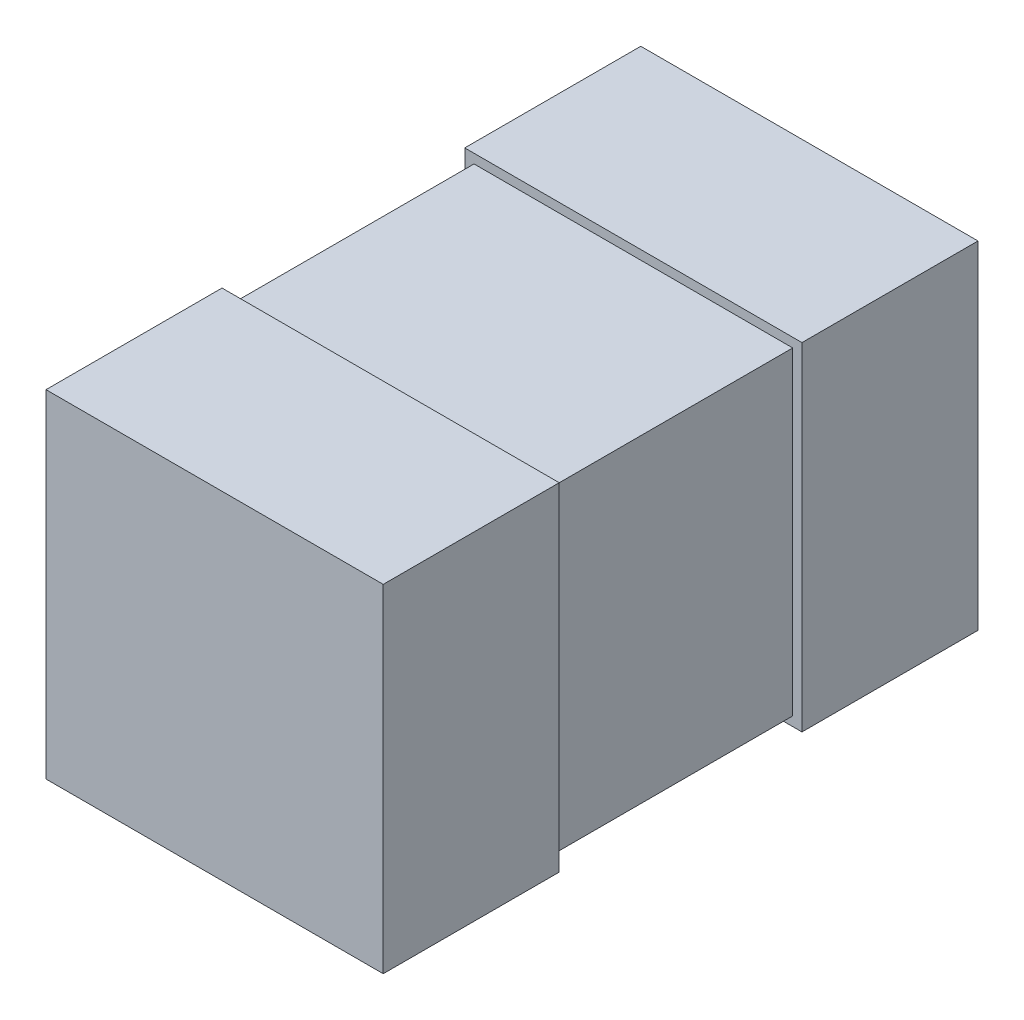
from build123d import *

# Parameters (mm, degrees)
SKETCH2_W           = 1.82
SKETCH2_H           = 0.95
BOSS_EXTRUDE1_DEPTH = 1.82
SKETCH4_W           = 1.72
SKETCH4_H           = 1.72
BOSS_EXTRUDE2_DEPTH = 1.31
SKETCH5_W           = 1.82
SKETCH5_H           = 1.82
BOSS_EXTRUDE3_DEPTH = 0.95


with BuildPart() as part:
    # Sketch2 → Boss-Extrude1 (new body)
    with BuildSketch(Plane(origin=(0, 0, 0), x_dir=(1, 0, 0), z_dir=(0, 1, 0))):
        with Locations((0, -1.13)):
            Rectangle(SKETCH2_W, SKETCH2_H)
    extrude(amount=BOSS_EXTRUDE1_DEPTH)


with BuildPart() as body_2:
    # Sketch4 → Boss-Extrude2 (new body)
    with BuildSketch(Plane(origin=(0, 0, 0.655), x_dir=(-1, 0, 0), z_dir=(0, 0, -1))):
        with Locations((0, 0.91)):
            Rectangle(SKETCH4_W, SKETCH4_H)
    extrude(amount=BOSS_EXTRUDE2_DEPTH)


with BuildPart() as body_3:
    # Sketch5 → Boss-Extrude3 (new body)
    with BuildSketch(Plane(origin=(0, 0, -0.655), x_dir=(-1, 0, 0), z_dir=(0, 0, -1))):
        with Locations((0, 0.91)):
            Rectangle(SKETCH5_W, SKETCH5_H)
    extrude(amount=BOSS_EXTRUDE3_DEPTH)


solid = Compound([part.part, body_2.part, body_3.part])
